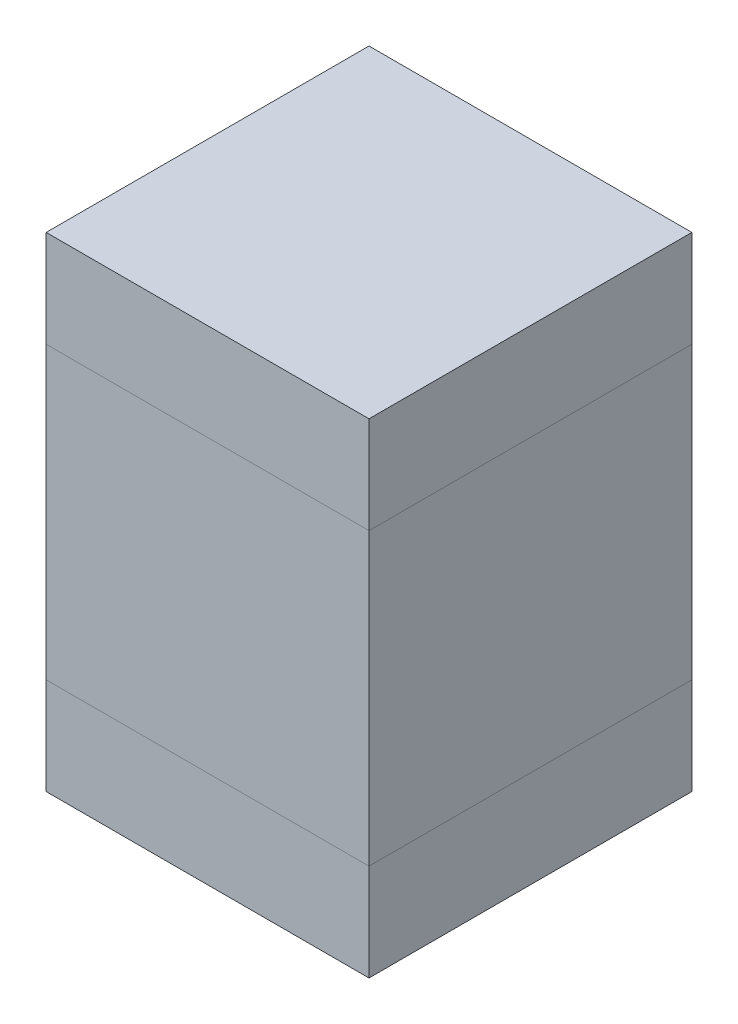
from build123d import *

# Parameters (mm, degrees)
SKETCH2_W           = 50
SKETCH2_H           = 50
BOSS_EXTRUDE1_DEPTH = 15
BOSS_EXTRUDE2_START = 15
SKETCH2_2_W         = 50
SKETCH2_2_H         = 50
BOSS_EXTRUDE2_DEPTH = 45
BOSS_EXTRUDE3_START = 60
SKETCH2_3_W         = 50
SKETCH2_3_H         = 50
BOSS_EXTRUDE3_DEPTH = 15


with BuildPart() as part:
    # Sketch2 → Boss-Extrude1 (new body)
    with BuildSketch(Plane(origin=(0, 0, 0), x_dir=(1, 0, 0), z_dir=(0, 1, 0))):
        Rectangle(SKETCH2_W, SKETCH2_H)
    extrude(amount=BOSS_EXTRUDE1_DEPTH)


with BuildPart() as body_2:
    # Sketch2_2 → Boss-Extrude2 (new body)
    with BuildSketch(Plane(origin=(0, 0, 0), x_dir=(1, 0, 0), z_dir=(0, 1, 0)).offset(BOSS_EXTRUDE2_START)):
        Rectangle(SKETCH2_2_W, SKETCH2_2_H)
    extrude(amount=BOSS_EXTRUDE2_DEPTH)


with BuildPart() as body_3:
    # Sketch2_3 → Boss-Extrude3 (new body)
    with BuildSketch(Plane(origin=(0, 0, 0), x_dir=(1, 0, 0), z_dir=(0, 1, 0)).offset(BOSS_EXTRUDE3_START)):
        Rectangle(SKETCH2_3_W, SKETCH2_3_H)
    extrude(amount=BOSS_EXTRUDE3_DEPTH)


solid = Compound([part.part, body_2.part, body_3.part])
